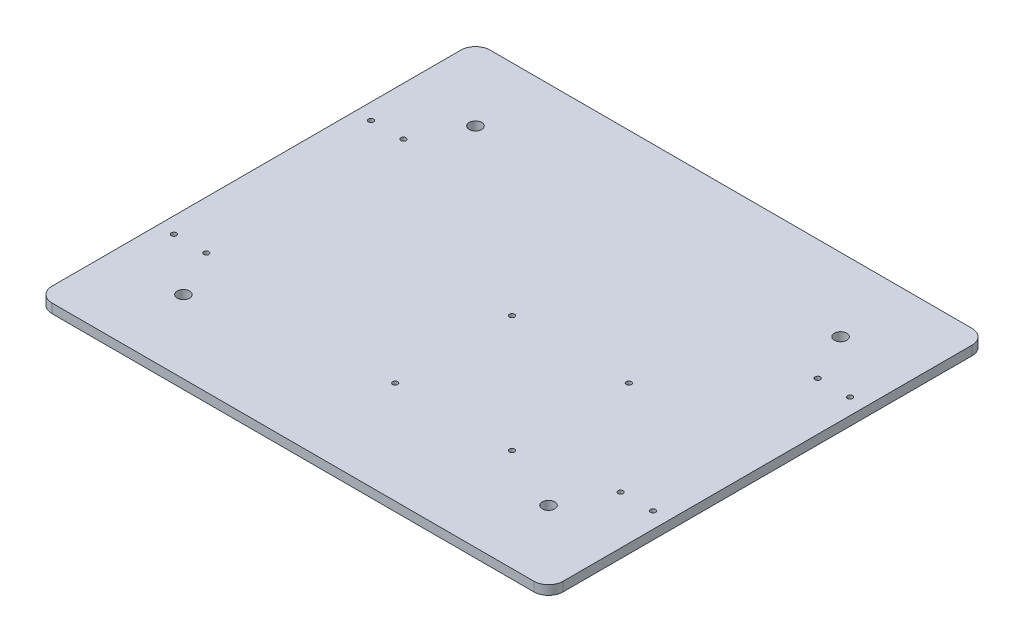
from build123d import *

# Parameters (mm, degrees)
SKETCH1_W                 = 350
SKETCH1_H                 = 300
BOSS_EXTRUDE1_DEPTH       = 6.35
SKETCH2_R                 = 4.25
CUT_EXTRUDE1_DEPTH        = 7.35
LPATTERN2_COUNT           = 2
LPATTERN2_PITCH           = 200
LPATTERN3_COUNT           = 2
LPATTERN3_PITCH           = 250
LPATTERN3_COPY_1_SKETCH_R = 4.25
LPATTERN3_COPY_1_DEPTH    = 7.35
FILLET1_R                 = 10
SKETCH4_R                 = 1.75
CUT_EXTRUDE2_DEPTH        = 7.35
LPATTERN5_COUNT           = 2
LPATTERN5_PITCH           = 80
LPATTERN5_COUNT_DIR2      = 2
LPATTERN5_PITCH_DIR2      = 80
SKETCH5_R                 = 1.75
CUT_EXTRUDE3_DEPTH        = 7.35
LPATTERN6_COUNT           = 2
LPATTERN6_PITCH           = 22.23
LPATTERN6_COUNT_DIR2      = 2
LPATTERN6_PITCH_DIR2      = 135
SKETCH7_R                 = 1.75
CUT_EXTRUDE4_DEPTH        = 7.35
LPATTERN9_COUNT           = 2
LPATTERN9_PITCH           = 22.23
LPATTERN9_COUNT_DIR2      = 2
LPATTERN9_PITCH_DIR2      = 135


with BuildPart() as part:
    # Sketch1 → Boss-Extrude1 (new body)
    with BuildSketch(Plane(origin=(0, 0, 0), x_dir=(1, 0, 0), z_dir=(0, 1, 0))):
        Rectangle(SKETCH1_W, SKETCH1_H)
    extrude(amount=BOSS_EXTRUDE1_DEPTH)

    # Sketch2 → Cut-Extrude1 (cut, through all)
    with BuildSketch(Plane.XZ):
        with Locations((-125, -100)):
            Circle(SKETCH2_R)
    cut_extrude1 = extrude(amount=-CUT_EXTRUDE1_DEPTH, mode=Mode.SUBTRACT)

    # LPattern2: Cut-Extrude1 ×2
    with Locations(*[(0, 0, i * LPATTERN2_PITCH) for i in range(1, LPATTERN2_COUNT)]):
        add(cut_extrude1, mode=Mode.SUBTRACT)

    # LPattern3: Cut-Extrude1 ×2
    with Locations(*[(i * LPATTERN3_PITCH, 0, 0) for i in range(1, LPATTERN3_COUNT)]):
        add(cut_extrude1, mode=Mode.SUBTRACT)

    # LPattern3 copy 1 sketch → LPattern3 copy 1 (cut, through all)
    with BuildSketch(Plane(origin=(250, 0, 200), x_dir=(1, 0, 0), z_dir=(0, -1, 0))):
        with Locations((-125, -100)):
            Circle(LPATTERN3_COPY_1_SKETCH_R)
    extrude(amount=-LPATTERN3_COPY_1_DEPTH, mode=Mode.SUBTRACT)

    # Fillet1
    fillet1_edges = [part.edges().sort_by_distance(p)[0] for p in [
        (-175, 3.175, -150),
        (175, 3.175, -150),
        (175, 3.175, 150),
        (-175, 3.175, 150),
    ]]
    fillet(fillet1_edges, radius=FILLET1_R)

    # Sketch4 → Cut-Extrude2 (cut, through all)
    with BuildSketch(Plane.XZ):
        Circle(SKETCH4_R)
    cut_extrude2 = extrude(amount=-CUT_EXTRUDE2_DEPTH, mode=Mode.SUBTRACT)

    # LPattern5: Cut-Extrude2 2 × 2
    with Locations(*[(i * LPATTERN5_PITCH, 0, j * LPATTERN5_PITCH_DIR2) for i in range(LPATTERN5_COUNT) for j in range(LPATTERN5_COUNT_DIR2) if (i, j) != (0, 0)]):
        add(cut_extrude2, mode=Mode.SUBTRACT)

    # Sketch5 → Cut-Extrude3 (cut, through all)
    with BuildSketch(Plane.XZ):
        with Locations((-141.82, -67.5)):
            Circle(SKETCH5_R)
    cut_extrude3 = extrude(amount=-CUT_EXTRUDE3_DEPTH, mode=Mode.SUBTRACT)

    # LPattern6: Cut-Extrude3 2 × 2
    with Locations(*[(-i * LPATTERN6_PITCH, 0, j * LPATTERN6_PITCH_DIR2) for i in range(LPATTERN6_COUNT) for j in range(LPATTERN6_COUNT_DIR2) if (i, j) != (0, 0)]):
        add(cut_extrude3, mode=Mode.SUBTRACT)

    # Sketch7 → Cut-Extrude4 (cut, through all)
    with BuildSketch(Plane.XZ):
        with Locations((141.82, -67.5)):
            Circle(SKETCH7_R)
    cut_extrude4 = extrude(amount=-CUT_EXTRUDE4_DEPTH, mode=Mode.SUBTRACT)

    # LPattern9: Cut-Extrude4 2 × 2
    with Locations(*[(i * LPATTERN9_PITCH, 0, j * LPATTERN9_PITCH_DIR2) for i in range(LPATTERN9_COUNT) for j in range(LPATTERN9_COUNT_DIR2) if (i, j) != (0, 0)]):
        add(cut_extrude4, mode=Mode.SUBTRACT)


solid = part.part
